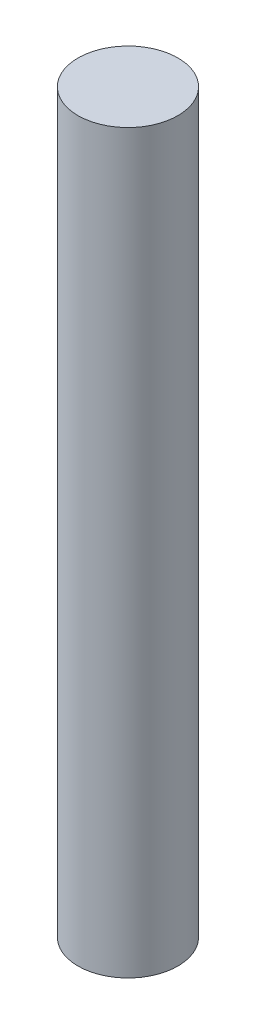
from build123d import *

# Parameters (mm, degrees)
SKETCH1_R           = 27.199999956
BOSS_EXTRUDE1_DEPTH = 400.999999878


with BuildPart() as part:
    # Sketch1 → Boss-Extrude1 (new body)
    with BuildSketch(Plane(origin=(0, 0, 0), x_dir=(1, 0, 0), z_dir=(0, 1, 0))):
        Circle(SKETCH1_R)
    extrude(amount=BOSS_EXTRUDE1_DEPTH)


solid = part.part
